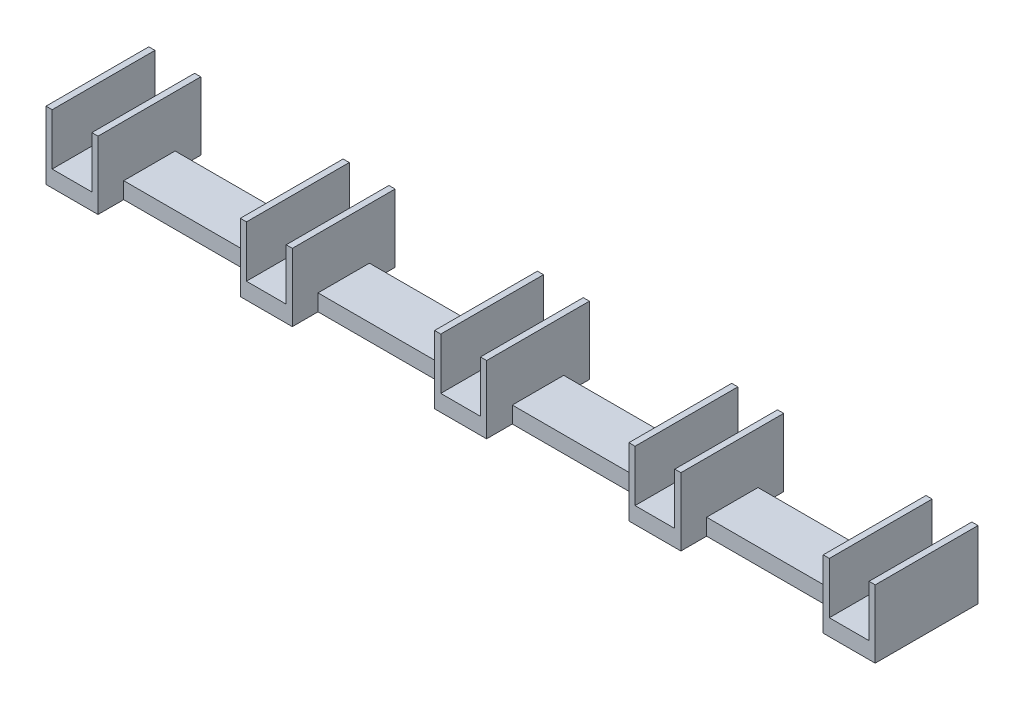
from build123d import *

# Parameters (mm, degrees)
SKIZZE1_W                       = 7.72
SKIZZE1_H                       = 10
SKIZZE1_W_2                     = 1.2
SKIZZE1_H_2                     = 20
SKIZZE1_W_3                     = 27.68
SKIZZE1_H_3                     = 5
AUFSATZ_LINEAR_AUSTRAGEN5_DEPTH = 3.2
SKIZZE2_W                       = 1.2
SKIZZE2_H                       = 20
AUFSATZ_LINEAR_AUSTRAGEN6_DEPTH = 10


with BuildPart() as part:
    # Skizze1 → Aufsatz-Linear austragen5 (new body)
    with BuildSketch(Plane(origin=(0, 0, 0), x_dir=(1, 0, 0), z_dir=(0, 1, 0))):
        with Locations((3.86, 15)):
            Rectangle(SKIZZE1_W, SKIZZE1_H)
        with Locations((-0.6, 10)):
            Rectangle(SKIZZE1_W_2, SKIZZE1_H_2)
        with Locations((3.86, 5)):
            Rectangle(SKIZZE1_W, SKIZZE1_H)
        Polygon((8.92, 20), (7.72, 20), (7.72, 10), (8.92, 10), (8.92, 15), align=None)
        Polygon((8.92, 10), (7.72, 10), (7.72, 0), (8.92, 0), (8.92, 5), align=None)
        with Locations((22.76, 12.5)):
            Rectangle(SKIZZE1_W_3, SKIZZE1_H_3)
        with Locations((22.76, 7.5)):
            Rectangle(SKIZZE1_W_3, SKIZZE1_H_3)
        Polygon((36.6, 20), (36.6, 15), (36.6, 10), (37.8, 10), (37.8, 20), align=None)
        Polygon((37.8, 10), (36.6, 10), (36.6, 5), (36.6, 0), (37.8, 0), align=None)
        with Locations((41.66, 15)):
            Rectangle(SKIZZE1_W, SKIZZE1_H)
        Polygon((45.52, 20), (45.52, 10), (46.72, 10), (46.72, 15), (46.72, 20), align=None)
        Polygon((46.72, 10), (45.52, 10), (45.52, 0), (46.72, 0), (46.72, 5), align=None)
        with Locations((41.66, 5)):
            Rectangle(SKIZZE1_W, SKIZZE1_H)
        with Locations((60.56, 12.5)):
            Rectangle(SKIZZE1_W_3, SKIZZE1_H_3)
        with Locations((60.56, 7.5)):
            Rectangle(SKIZZE1_W_3, SKIZZE1_H_3)
        with Locations((79.46, 15)):
            Rectangle(SKIZZE1_W, SKIZZE1_H)
        Polygon((74.4, 15), (74.4, 10), (75.6, 10), (75.6, 20), (74.4, 20), align=None)
        Polygon((75.6, 10), (74.4, 10), (74.4, 5), (74.4, 0), (75.6, 0), align=None)
        with Locations((79.46, 5)):
            Rectangle(SKIZZE1_W, SKIZZE1_H)
        Polygon((83.32, 20), (83.32, 10), (84.52, 10), (84.52, 15), (84.52, 20), align=None)
        Polygon((84.52, 10), (83.32, 10), (83.32, 0), (84.52, 0), (84.52, 5), align=None)
        with Locations((98.36, 12.5)):
            Rectangle(SKIZZE1_W_3, SKIZZE1_H_3)
        with Locations((98.36, 7.5)):
            Rectangle(SKIZZE1_W_3, SKIZZE1_H_3)
        with Locations((117.26, 15)):
            Rectangle(SKIZZE1_W, SKIZZE1_H)
        Polygon((112.2, 15), (112.2, 10), (113.4, 10), (113.4, 20), (112.2, 20), align=None)
        Polygon((113.4, 10), (112.2, 10), (112.2, 5), (112.2, 0), (113.4, 0), align=None)
        Polygon((121.12, 20), (121.12, 10), (122.32, 10), (122.32, 15), (122.32, 20), align=None)
        with Locations((117.26, 5)):
            Rectangle(SKIZZE1_W, SKIZZE1_H)
        Polygon((122.32, 10), (121.12, 10), (121.12, 0), (122.32, 0), (122.32, 5), align=None)
        with Locations((136.16, 12.5)):
            Rectangle(SKIZZE1_W_3, SKIZZE1_H_3)
        with Locations((136.16, 7.5)):
            Rectangle(SKIZZE1_W_3, SKIZZE1_H_3)
        Polygon((150, 15), (150, 10), (151.2, 10), (151.2, 20), (150, 20), align=None)
        Polygon((151.2, 10), (150, 10), (150, 5), (150, 0), (151.2, 0), align=None)
        with Locations((155.06, 15)):
            Rectangle(SKIZZE1_W, SKIZZE1_H)
        with Locations((159.52, 15)):
            Rectangle(SKIZZE1_W_2, SKIZZE1_H)
        with Locations((155.06, 5)):
            Rectangle(SKIZZE1_W, SKIZZE1_H)
        with Locations((159.52, 5)):
            Rectangle(SKIZZE1_W_2, SKIZZE1_H)
    extrude(amount=AUFSATZ_LINEAR_AUSTRAGEN5_DEPTH)

    # Skizze2 → Aufsatz-Linear austragen6 (add)
    with BuildSketch(Plane(origin=(0, 3.2, 0), x_dir=(1, 0, 0), z_dir=(0, 1, 0))):
        with Locations((8.32, 10)):
            Rectangle(SKIZZE2_W, SKIZZE2_H)
        with Locations((-0.6, 10)):
            Rectangle(SKIZZE2_W, SKIZZE2_H)
        with Locations((37.2, 10)):
            Rectangle(SKIZZE2_W, SKIZZE2_H)
        with Locations((46.12, 10)):
            Rectangle(SKIZZE2_W, SKIZZE2_H)
        with Locations((75, 10)):
            Rectangle(SKIZZE2_W, SKIZZE2_H)
        with Locations((83.92, 10)):
            Rectangle(SKIZZE2_W, SKIZZE2_H)
        with Locations((112.8, 10)):
            Rectangle(SKIZZE2_W, SKIZZE2_H)
        with Locations((121.72, 10)):
            Rectangle(SKIZZE2_W, SKIZZE2_H)
        with Locations((150.6, 10)):
            Rectangle(SKIZZE2_W, SKIZZE2_H)
        with Locations((159.52, 10)):
            Rectangle(SKIZZE2_W, SKIZZE2_H)
    extrude(amount=AUFSATZ_LINEAR_AUSTRAGEN6_DEPTH)


solid = part.part
